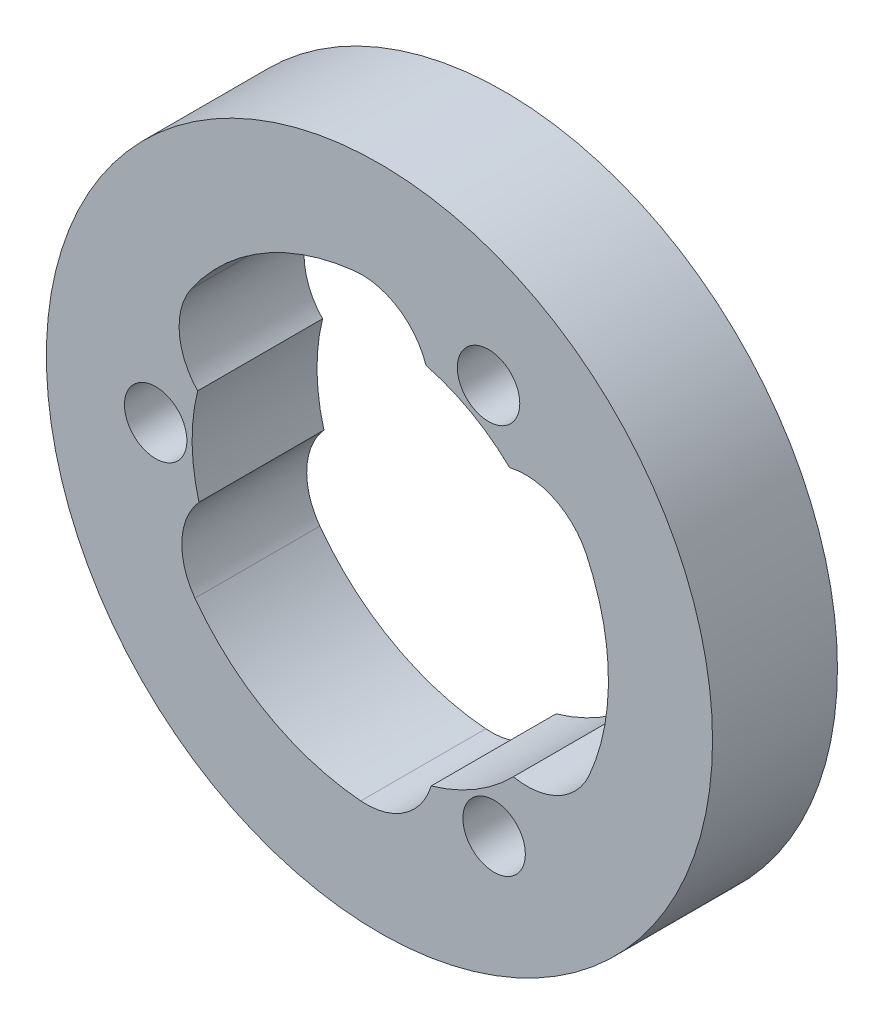
from build123d import *

# Parameters (mm, degrees)
ESQUISSE1_R        = 16
ESQUISSE1_R_2      = 1.5
BOSS_EXTRU_1_DEPTH = 6


with BuildPart() as part:
    # Esquisse1 → Boss.-Extru.1 (new body)
    with BuildSketch(Plane.XY):
        Circle(ESQUISSE1_R)
        with Locations((-10.748886558, -0.154718329)):
            Circle(ESQUISSE1_R_2, mode=Mode.SUBTRACT)
        with Locations((5.240453276, 9.386167986)):
            Circle(ESQUISSE1_R_2, mode=Mode.SUBTRACT)
        with Locations((5.508433282, -9.231449657)):
            Circle(ESQUISSE1_R_2, mode=Mode.SUBTRACT)
        with BuildLine():
            ThreePointArc((-8.667289778, -2.424476831), (-9.490533908, -4.435287826), (-8.862790309, -6.515439198))
            ThreePointArc((-8.862790309, -6.515439198), (-5.362324282, -9.604450963), (-0.895963785, -10.963450593))
            ThreePointArc((-0.895963785, -10.963450593), (1.204207331, -10.406339254), (2.483990345, -8.650421491))
            ThreePointArc((2.483990345, -8.650421491), (4.611711585, -7.728655527), (6.433303415, -6.293854715))
            ThreePointArc((6.433303415, -6.293854715), (8.586338885, -6.001399547), (10.073931017, -4.417681957))
            ThreePointArc((10.073931017, -4.417681957), (10.998860664, 0.15831643), (9.942608619, 4.705797898))
            ThreePointArc((9.942608619, 4.705797898), (8.410050489, 6.246043767), (6.249489591, 6.476409487))
            ThreePointArc((6.249489591, 6.476409487), (4.387356231, 7.858187151), (2.233986363, 8.718331545))
            ThreePointArc((2.233986363, 8.718331545), (0.904195024, 10.436687373), (-1.211140708, 10.933121155))
            ThreePointArc((-1.211140708, 10.933121155), (-5.636536382, 9.446134533), (-9.046644834, 6.257652695))
            ThreePointArc((-9.046644834, 6.257652695), (-9.61425782, 4.160295487), (-8.733479937, 2.174012003))
            ThreePointArc((-8.733479937, 2.174012003), (-8.999067816, -0.129531624), (-8.667289778, -2.424476831))
        make_face(mode=Mode.SUBTRACT)
    extrude(amount=BOSS_EXTRU_1_DEPTH)


solid = part.part
